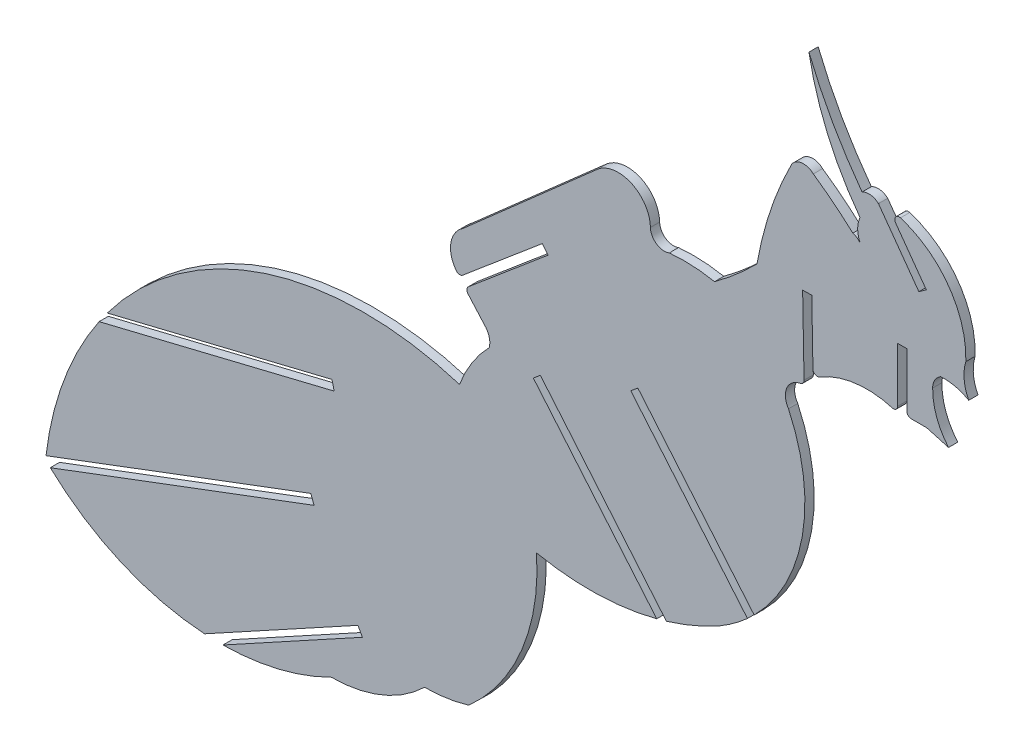
from build123d import *

# Parameters (mm, degrees)
BOSS_EXTRUDE1_DEPTH = 1.524
CUT_EXTRUDE1_DEPTH  = 1.524
CUT_EXTRUDE2_DEPTH  = 1.524


with BuildPart() as part:
    # Sketch1 → Boss-Extrude1 (new body)
    with BuildSketch(Plane.XY):
        with BuildLine():
            Line((-18.109082737, 18.651136583), (-40.403888228, -0.992394741))
            ThreePointArc((-40.403888228, -0.992394741), (-42.395698567, -4.050724761), (-41.491876636, -7.586795582))
            ThreePointArc((-41.491876636, -7.586795582), (-40.996783491, -7.860427406), (-40.456184155, -7.693862236))
            Line((-40.456184155, -7.693862236), (-27.338891186, 3.372084587))
            Line((-27.338891186, 3.372084587), (-26.367560741, 2.220467499))
            Line((-26.367560741, 2.220467499), (-39.509764326, -8.866336125))
            ThreePointArc((-39.509764326, -8.866336125), (-39.764677025, -9.366363056), (-39.585096423, -9.898113208))
            Line((-39.585096423, -9.898113208), (-36.909039408, -12.923145527))
            ThreePointArc((-36.909039408, -12.923145527), (-36.096292723, -14.255273478), (-36.065454443, -15.815456497))
            ThreePointArc((-36.065454443, -15.815456497), (-38.919913552, -19.419117177), (-40.970693325, -23.533556316))
            ThreePointArc((-40.970693325, -23.533556316), (-85.68561882, -29.806279301), (-109.164446531, -68.374611713))
            ThreePointArc((-109.164446531, -68.374611713), (-86.824997617, -79.693885154), (-62.075353147, -75.868701805))
            ThreePointArc((-62.075353147, -75.868701805), (-53.793448225, -74.248732285), (-46.732322194, -69.627612338))
            ThreePointArc((-46.732322194, -69.627612338), (-43.045880581, -69.354101873), (-39.440165524, -68.539559875))
            ThreePointArc((-39.440165524, -68.539559875), (-30.674096062, -56.183483706), (-28.287271549, -41.22288008))
            ThreePointArc((-28.287271549, -41.22288008), (-18.354497785, -42.11718557), (-8.478792941, -40.727858108))
            Line((-8.478792941, -40.727858108), (-28.809143223, -16.540912603))
            Line((-28.809143223, -16.540912603), (-27.655597936, -15.571510358))
            Line((-27.655597936, -15.571510358), (-6.888329643, -40.281661868))
            ThreePointArc((-6.888329643, -40.281661868), (-2.393348388, -38.654039316), (1.896097193, -36.543430812))
            ThreePointArc((1.896097193, -36.543430812), (14.669066503, -20.423756748), (13.224183609, 0.092211431))
            ThreePointArc((13.224183609, 0.092211431), (12.94908113, 2.915517355), (15.164401866, 4.687265575))
            ThreePointArc((15.164401866, 4.687265575), (15.618518122, 4.953772723), (15.791401816, 5.451124573))
            Line((15.791401816, 5.451124573), (15.559206878, 18.186922579))
            Line((15.559206878, 18.186922579), (17.065612654, 18.214399421))
            Line((17.065612654, 18.214399421), (17.255673973, 7.790267081))
            ThreePointArc((17.255673973, 7.790267081), (17.649146232, 7.159803879), (18.390670497, 7.209261245))
            ThreePointArc((18.390670497, 7.209261245), (24.284101701, 9.245801019), (30.497638202, 8.724274642))
            ThreePointArc((30.497638202, 8.724274642), (31.008729101, 8.935857556), (31.220713438, 9.446782089))
            Line((31.220713438, 9.446782089), (31.227755152, 18.421680855))
            Line((31.227755152, 18.421680855), (32.734160928, 18.420716756))
            Line((32.734160928, 18.420716756), (32.727120315, 9.492749656))
            ThreePointArc((32.727120315, 9.492749656), (32.938701818, 8.981090412), (33.450193713, 8.769104665))
            Line((33.450193713, 8.769104665), (36.00103405, 8.76910061))
            Line((36.00103405, 8.76910061), (39.593571682, 7.750734608))
            ThreePointArc((39.593571682, 7.750734608), (37.634153074, 11.103388424), (36.980980252, 14.931308767))
            ThreePointArc((36.980980252, 14.931308767), (37.32973025, 16.244488278), (38.290753444, 17.204957649))
            ThreePointArc((38.290753444, 17.204957649), (40.689125585, 17.029816962), (42.926139447, 16.147415598))
            ThreePointArc((42.926139447, 16.147415598), (42.166781774, 18.73974704), (42.447864883, 21.426343152))
            ThreePointArc((42.447864883, 21.426343152), (39.616652478, 30.812755933), (31.670318465, 36.555254025))
            ThreePointArc((31.670318465, 36.555254025), (30.869545829, 36.286258041), (30.870312564, 35.441512478))
            Line((30.870312564, 35.441512478), (35.931597573, 28.422287011))
            Line((35.931597573, 28.422287011), (34.710083257, 27.541099888))
            Line((34.710083257, 27.541099888), (28.048154351, 36.779585234))
            ThreePointArc((28.048154351, 36.779585234), (26.749368414, 37.368488779), (25.351600254, 37.085829151))
            ThreePointArc((25.351600254, 37.085829151), (20.481432232, 44.59849919), (16.594043627, 52.663668593))
            ThreePointArc((16.594043627, 52.663668593), (19.678771518, 42.480420055), (25.014453648, 33.274737399))
            ThreePointArc((25.014453648, 33.274737399), (24.630642645, 31.475856238), (25.014447927, 29.676973856))
            ThreePointArc((25.014447927, 29.676973856), (24.481307432, 30.159012342), (23.8292382, 30.461345943))
            ThreePointArc((23.8292382, 30.461345943), (20.663534908, 33.163038536), (17.321589669, 35.643405891))
            ThreePointArc((17.321589669, 35.643405891), (15.461285039, 36.273044307), (13.767992132, 35.278088539))
            ThreePointArc((13.767992132, 35.278088539), (10.258583377, 26.939942946), (8.042121541, 18.169086735))
            ThreePointArc((8.042121541, 18.169086735), (4.666584105, 15.017884217), (1.052433145, 12.143472427))
            ThreePointArc((1.052433145, 12.143472427), (-2.67031295, 12.596290492), (-6.419385375, 12.504974353))
            ThreePointArc((-6.419385375, 12.504974353), (-8.511533948, 12.739347863), (-9.521951073, 14.586257126))
            ThreePointArc((-9.521951073, 14.586257126), (-12.55527012, 19.280991071), (-18.109082737, 18.651136583))
        make_face()
    extrude(amount=BOSS_EXTRUDE1_DEPTH)

    # Sketch2 → Cut-Extrude1 (cut)
    with BuildSketch(Plane(origin=(0, 0, 0), x_dir=(-1, 0, 0), z_dir=(0, 0, -1))):
        Polygon((-7.412304672, -34.333896752), (12.756455248, -10.335886692), (11.589770834, -9.355364649), (-8.578989086, -33.353374708), align=None)
    extrude(amount=-CUT_EXTRUDE1_DEPTH, mode=Mode.SUBTRACT)

    # Sketch3 → Cut-Extrude2 (cut)
    with BuildSketch(Plane(origin=(0, 0, 0), x_dir=(-1, 0, 0), z_dir=(0, 0, -1))):
        Polygon((92.239440666, -85.195390194), (57.69869779, -66.269905982), (56.966391259, -67.606432504), (91.507134135, -86.531916716), align=None)
        Polygon((113.568916303, -69.443616856), (65.468307652, -51.334573831), (64.931342073, -52.760843078), (113.031950724, -70.869886103), align=None)
        Polygon((103.892541474, -43.556614737), (61.98194232, -33.329554282), (61.620655619, -34.810110907), (103.531254772, -45.037171362), align=None)
    extrude(amount=-CUT_EXTRUDE2_DEPTH, mode=Mode.SUBTRACT)


solid = part.part
